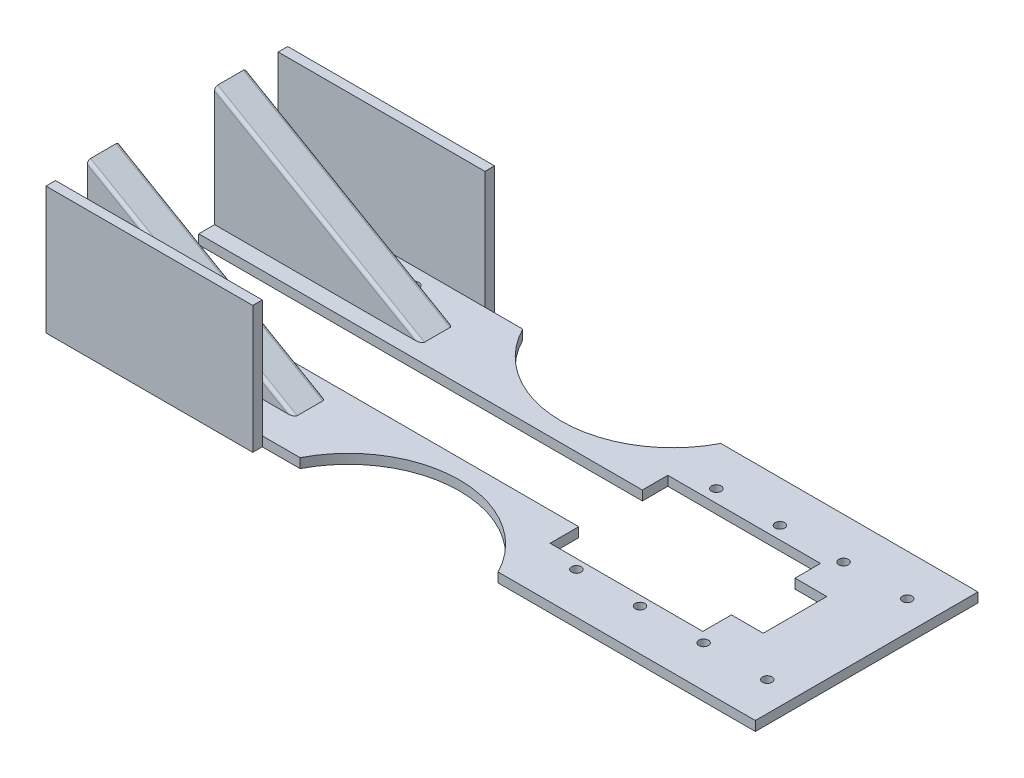
from build123d import *

# Parameters (mm, degrees)
SKETCH_1_W           = 220
SKETCH_1_H           = 70
EXTRUDE_1_DEPTH      = 3
EXTRUDE_2_DEPTH      = 25
EXTRUDE_2_DEPTH_BACK = 25
SKETCH_6_W           = 30
SKETCH_6_H           = 37.527767497
CUT_EXTRUDE_4_DEPTH  = 221
SKETCH_7_R           = 35
CUT_EXTRUDE_5_DEPTH  = 4
SKETCH_8_W           = 3
SKETCH_8_H           = 40
EXTRUDE_3_DEPTH      = 65
SKETCH_9_R           = 1.5
CUT_EXTRUDE_6_DEPTH  = 4
FILLET_5_R           = 1
SKETCH_10_W          = 65
SKETCH_10_H          = 20
CUT_EXTRUDE_7_DEPTH  = 4
SKETCH_11_W          = 132.48262102
SKETCH_11_H          = 20
CUT_EXTRUDE_8_DEPTH  = 25
SKETCH_12_W          = 48
SKETCH_12_H          = 37
CUT_EXTRUDE_9_DEPTH  = 30


with BuildPart() as part:
    # 草图1 → 凸台-拉伸1 (new body)
    with BuildSketch(Plane(origin=(0, 0, 0), x_dir=(1, 0, 0), z_dir=(0, 1, 0))):
        with Locations((27.295373665, 0)):
            Rectangle(SKETCH_1_W, SKETCH_1_H)
    extrude(amount=EXTRUDE_1_DEPTH)

    # 草图2 → 凸台-拉伸2 (add, two sides)
    with BuildSketch(Plane.XY) as extrude_2_sk:
        Polygon((-82.704626335, 40.527767497), (-82.704626335, 3), (-17.704626335, 3), align=None)
    extrude(amount=EXTRUDE_2_DEPTH)
    extrude(extrude_2_sk.sketch, amount=-EXTRUDE_2_DEPTH_BACK)

    # 草图6 → 切除-拉伸4 (cut, through all)
    with BuildSketch(Plane.ZY.offset(82.704626335)):
        with Locations((0, 21.763883748)):
            Rectangle(SKETCH_6_W, SKETCH_6_H)
    extrude(amount=-CUT_EXTRUDE_4_DEPTH, mode=Mode.SUBTRACT)

    # 草图7 → 切除-拉伸5 (cut, through all)
    with BuildSketch(Plane(origin=(0, 3, 0), x_dir=(1, 0, 0), z_dir=(0, 1, 0))):
        with Locations((25.295373665, 51)):
            Circle(SKETCH_7_R)
        with Locations((25.295373665, -51)):
            Circle(SKETCH_7_R)
    extrude(amount=-CUT_EXTRUDE_5_DEPTH, mode=Mode.SUBTRACT)

    # 草图8 → 凸台-拉伸3 (add)
    with BuildSketch(Plane.ZY.offset(82.704626335)):
        with Locations((36.5, 20)):
            Rectangle(SKETCH_8_W, SKETCH_8_H)
        with Locations((-36.5, 20)):
            Rectangle(SKETCH_8_W, SKETCH_8_H)
    extrude(amount=-EXTRUDE_3_DEPTH)

    # 草图9 → 切除-拉伸6 (cut, through all)
    with BuildSketch(Plane(origin=(0, 3, 0), x_dir=(1, 0, 0), z_dir=(0, 1, 0))):
        with Locations((-74.766784803, 29.860059225)):
            Circle(SKETCH_9_R)
        with Locations((-54.766784803, 29.860059225)):
            Circle(SKETCH_9_R)
        with Locations((-34.766784803, 29.860059225)):
            Circle(SKETCH_9_R)
        with Locations((-34.766784803, -29.860059225)):
            Circle(SKETCH_9_R)
        with Locations((-54.766784803, -29.860059225)):
            Circle(SKETCH_9_R)
        with Locations((-74.766784803, -29.860059225)):
            Circle(SKETCH_9_R)
        with Locations((68.031562246, 22)):
            Circle(SKETCH_9_R)
        with Locations((88.031562246, 22)):
            Circle(SKETCH_9_R)
        with Locations((108.031562246, 22)):
            Circle(SKETCH_9_R)
        with Locations((108.031562246, -22)):
            Circle(SKETCH_9_R)
        with Locations((88.031562246, -22)):
            Circle(SKETCH_9_R)
        with Locations((68.031562246, -22)):
            Circle(SKETCH_9_R)
        with Locations((128.031562246, 22)):
            Circle(SKETCH_9_R)
        with Locations((128.031562246, -22)):
            Circle(SKETCH_9_R)
    extrude(amount=-CUT_EXTRUDE_6_DEPTH, mode=Mode.SUBTRACT)

    # 圆角5
    fillet_5_edges = [part.edges().sort_by_distance(p)[0] for p in [
        (-50.204626335, 21.763883749, -25),
        (-50.204626335, 21.763883749, 25),
        (-50.204626335, 21.763883749, -15),
        (-50.204626335, 21.763883749, 15),
    ]]
    fillet(fillet_5_edges, radius=FILLET_5_R)

    # 草图10 → 切除-拉伸7 (cut, through all)
    with BuildSketch(Plane(origin=(0, 3, 0), x_dir=(1, 0, 0), z_dir=(0, 1, 0))):
        with Locations((-50.204626335, 0)):
            Rectangle(SKETCH_10_W, SKETCH_10_H)
    extrude(amount=-CUT_EXTRUDE_7_DEPTH, mode=Mode.SUBTRACT)

    # 草图11 → 切除-拉伸8 (cut)
    with BuildSketch(Plane(origin=(0, 0, 0), x_dir=(1, 0, 0), z_dir=(0, 1, 0))):
        with Locations((48.536684175, 0)):
            Rectangle(SKETCH_11_W, SKETCH_11_H)
    extrude(amount=CUT_EXTRUDE_8_DEPTH, mode=Mode.SUBTRACT)

    # 草图12 → 切除-拉伸9 (cut)
    with BuildSketch(Plane(origin=(0, 0, 0), x_dir=(1, 0, 0), z_dir=(0, 1, 0))):
        with Locations((80.777994685, -0.5)):
            Rectangle(SKETCH_12_W, SKETCH_12_H)
    extrude(amount=CUT_EXTRUDE_9_DEPTH, mode=Mode.SUBTRACT)


solid = part.part
